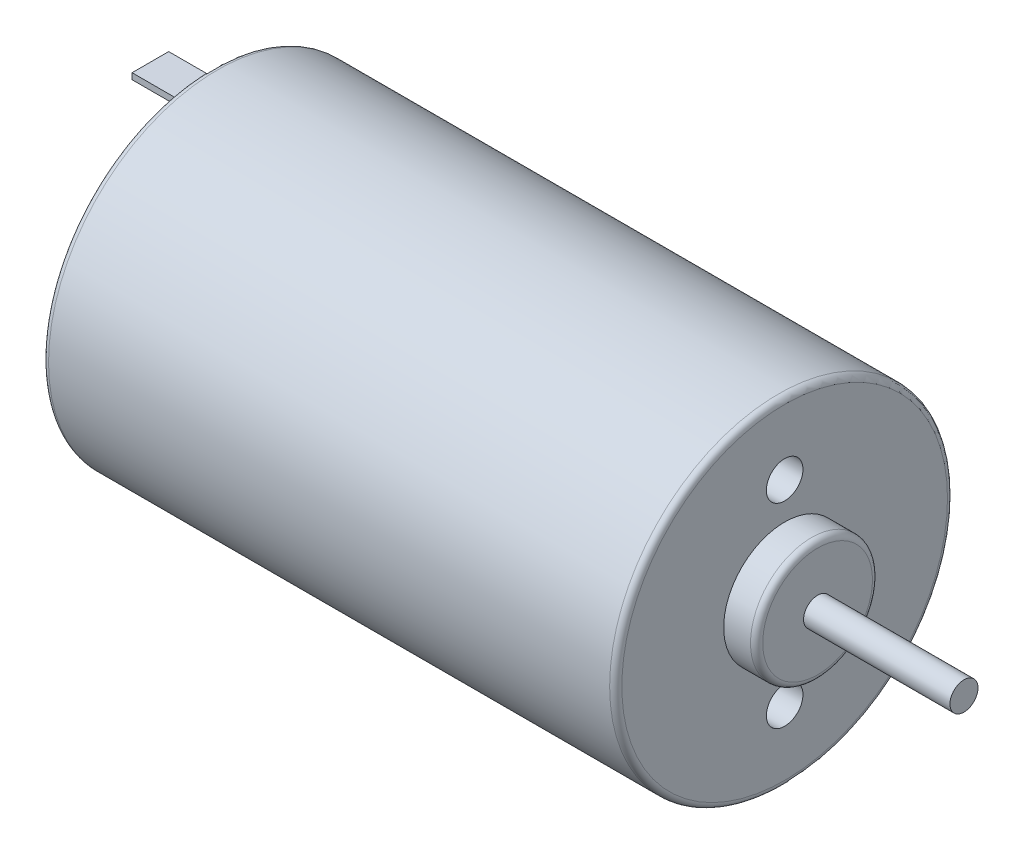
from build123d import *

# Parameters (mm, degrees)
SKETCH1_R           = 13.85
BOSS_EXTRUDE1_DEPTH = 47
SKETCH2_R           = 5
BOSS_EXTRUDE2_DEPTH = 2.7
SKETCH3_R           = 1.15
BOSS_EXTRUDE3_DEPTH = 12
SKETCH4_R           = 5
BOSS_EXTRUDE4_DEPTH = 2
SKETCH5_R           = 1.15
BOSS_EXTRUDE5_DEPTH = 0.75
SKETCH6_W           = 3
SKETCH6_H           = 0.5
BOSS_EXTRUDE6_DEPTH = 5
SKETCH7_R           = 1.5
CUT_EXTRUDE1_DEPTH  = 5
FILLET1_R           = 0.5


with BuildPart() as part:
    # Sketch1 → Boss-Extrude1 (new body)
    with BuildSketch(Plane(origin=(0, 0, 0), x_dir=(0, 0, -1), z_dir=(1, 0, 0))):
        Circle(SKETCH1_R)
    extrude(amount=BOSS_EXTRUDE1_DEPTH)

    # Sketch2 → Boss-Extrude2 (add)
    with BuildSketch(Plane(origin=(47, 0, 0), x_dir=(0, 0, -1), z_dir=(1, 0, 0))):
        Circle(SKETCH2_R)
    extrude(amount=BOSS_EXTRUDE2_DEPTH)

    # Sketch3 → Boss-Extrude3 (add)
    with BuildSketch(Plane(origin=(49.7, 0, 0), x_dir=(0, 0, -1), z_dir=(1, 0, 0))):
        Circle(SKETCH3_R)
    extrude(amount=BOSS_EXTRUDE3_DEPTH)

    # Sketch4 → Boss-Extrude4 (add)
    with BuildSketch(Plane.ZY):
        Circle(SKETCH4_R)
    extrude(amount=BOSS_EXTRUDE4_DEPTH)

    # Sketch5 → Boss-Extrude5 (add)
    with BuildSketch(Plane.ZY.offset(2)):
        Circle(SKETCH5_R)
    extrude(amount=BOSS_EXTRUDE5_DEPTH)

    # Sketch6 → Boss-Extrude6 (add)
    with BuildSketch(Plane.ZY):
        with Locations((0, 11.4)):
            Rectangle(SKETCH6_W, SKETCH6_H)
        with Locations((0, -11.4)):
            Rectangle(SKETCH6_W, SKETCH6_H)
    extrude(amount=BOSS_EXTRUDE6_DEPTH)

    # Sketch7 → Cut-Extrude1 (cut)
    with BuildSketch(Plane(origin=(47, 0, 0), x_dir=(0, 0, -1), z_dir=(1, 0, 0))):
        with Locations((0, 8)):
            Circle(SKETCH7_R)
        with Locations((0, -8)):
            Circle(SKETCH7_R)
    extrude(amount=-CUT_EXTRUDE1_DEPTH, mode=Mode.SUBTRACT)

    # Fillet1
    fillet1_edges = [part.edges().sort_by_distance(p)[0] for p in [
        (-2, 0, -5),
        (0, 0, 13.85),
        (47, 0, 13.85),
        (49.7, 0, 5),
    ]]
    fillet(fillet1_edges, radius=FILLET1_R)


solid = part.part
